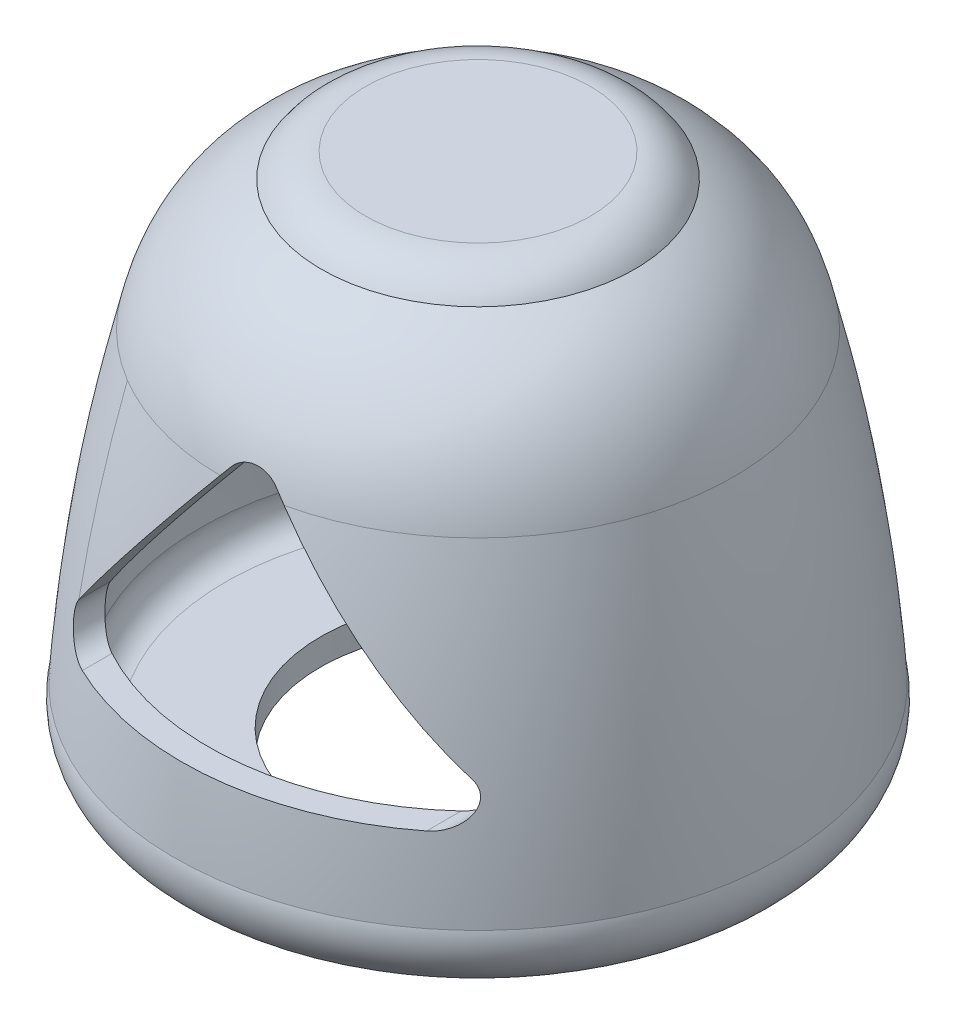
from build123d import *

# Parameters (mm, degrees)
CUT_EXTRUDE1_DEPTH = 90


with BuildPart() as part:
    # Sketch1 → Revolve1 (revolve)
    with BuildSketch(Plane.XY):
        with BuildLine():
            Line((-60, -20), (-96.125741133, -20))
            ThreePointArc((-96.125741133, -20), (-111.90029933, -12.294849071), (-115.520322353, 4.883668631))
            add(Edge.make_bspline(
                [(-115.520322353, 4.883668631), (-114.860979456, 14.70014017), (-113.11052441, 34.318769404), (-109.199978895, 63.5295318), (-104.005931933, 92.550933242), (-99.678127267, 111.804086778), (-97.30777954, 121.368144978)],
                knots=[0.008951531, 0.008951531, 0.008951531, 0.008951531, 0.256369468, 0.503787406, 0.751205343, 0.998623281, 0.998623281, 0.998623281, 0.998623281], degree=3))
            add(Edge.make_bspline(
                [(-97.30777954, 121.368144978), (-97.006815199, 122.771726667), (-96.33672337, 125.583838885), (-94.769340107, 130.993515427), (-92.353138405, 137.454230573), (-88.708671142, 144.660209635), (-84.309064749, 151.282776778), (-79.166039694, 157.266932305), (-73.313963281, 162.564089005), (-67.882699696, 166.380346203), (-63.240194345, 169.064821982), (-60.807660035, 170.292254493), (-59.580687569, 170.869851074)],
                knots=[0.002341757, 0.002341757, 0.002341757, 0.002341757, 0.061277741, 0.120213724, 0.238085692, 0.355957659, 0.473829627, 0.591701595, 0.709573562, 0.82744553, 0.886381513, 0.945317497, 0.945317497, 0.945317497, 0.945317497], degree=3))
            ThreePointArc((-59.580687569, 170.869851074), (-52.347589078, 177.569818176), (-42.792407799, 180))
            Line((-42.792407799, 180), (0, 180))
            Line((0, 180), (0, 170))
            Line((0, 170), (-42.792407799, 170))
            ThreePointArc((-42.792407799, 170), (-48.639510646, 168.112421852), (-52.27924078, 163.16227766))
            add(Edge.make_bspline(
                [(-87.562361975, 119.120125222), (-80.685582133, 151.474296581), (-52.27924078, 163.16227766)],
                knots=[0, 0, 0, 1, 1, 1], degree=2))
            add(Edge.make_bspline(
                [(-105.612574113, 3.16227766), (-101.761749879, 61.886899846), (-87.562361975, 119.120125222)],
                knots=[0, 0, 0, 1, 1, 1], degree=2))
            ThreePointArc((-105.612574113, 3.16227766), (-104.238162985, -5.847102847), (-96.125741133, -10))
            Line((-96.125741133, -10), (-60, -10))
            Line((-60, -10), (-60, -20))
        make_face()
    revolve(axis=Axis((0, 170, 0), (0, 1, 0)))

    # Sketch2 → Cut-Extrude1 (cut)
    with BuildSketch(Plane.XY.offset(120)):
        with BuildLine():
            Line((69.352345674, 35.146397343), (-49.035157376, 35.146397343))
            ThreePointArc((-49.035157376, 35.146397343), (-58.048189739, 40.814510039), (-56.843845471, 51.393347819))
            Line((-56.843845471, 51.393347819), (2.349906054, 125.385537225))
            ThreePointArc((2.349906054, 125.385537225), (10.158594149, 129.13858675), (17.967282243, 125.385537225))
            Line((17.967282243, 125.385537225), (77.161033768, 51.393347819))
            ThreePointArc((77.161033768, 51.393347819), (78.365378037, 40.814510039), (69.352345674, 35.146397343))
        make_face()
    extrude(amount=-CUT_EXTRUDE1_DEPTH, mode=Mode.SUBTRACT)


solid = part.part
